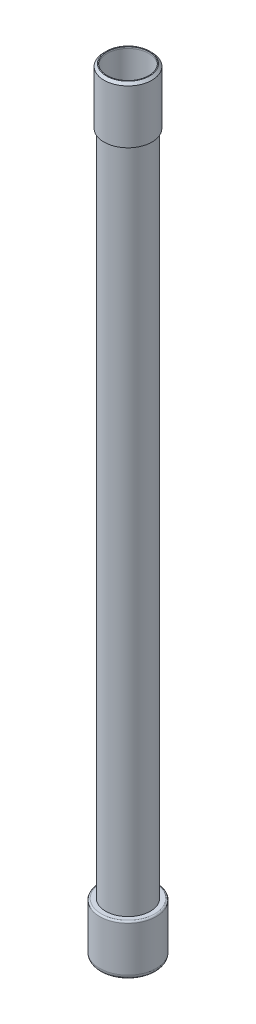
from build123d import *

# Parameters (mm, degrees)
SKETCH1_R      = 14
SKETCH1_R_2    = 13
EXTRUDE1_DEPTH = 240
FILLET1_R      = 3
FILLET2_R      = 1
CHAMFER1_SIZE  = 1.5


with BuildPart() as part:
    # Sketch1 → Extrude1 (new body, symmetric)
    with BuildSketch(Plane(origin=(0, 0, 0), x_dir=(1, 0, 0), z_dir=(0, 1, 0))):
        Circle(SKETCH1_R)
        Circle(SKETCH1_R_2, mode=Mode.SUBTRACT)
    extrude(amount=EXTRUDE1_DEPTH, both=True)


with BuildPart() as body_2:
    # Sketch2 → Revolve1 (revolve)
    with BuildSketch(Plane.XY):
        with BuildLine():
            Line((13, -211), (17.75, -211))
            Line((17.75, -211), (17.75, -242))
            ThreePointArc((17.75, -242), (9.097561486, -244.987616596), (0, -246))
            Line((0, -246), (0, -240))
            Line((0, -240), (13, -240))
            Line((13, -240), (13, -211))
        make_face()
    revolve(axis=Axis((0, -191.854456481, 0), (0, -1, 0)))

    # Fillet1
    fillet1_edges = [body_2.edges().sort_by_distance(p)[0] for p in [
        (-17.75, -242, 0),
    ]]
    fillet(fillet1_edges, radius=FILLET1_R)

    # Fillet2
    fillet2_edges = [body_2.edges().sort_by_distance(p)[0] for p in [
        (-17.75, -211, 0),
    ]]
    fillet(fillet2_edges, radius=FILLET2_R)


with BuildPart() as body_3:
    # Sketch3 → Revolve2 (revolve)
    with BuildSketch(Plane.XY):
        Polygon((15, 241), (15, 206), (14, 206), (14, 240), (13, 240), (13, 241), align=None)
    revolve(axis=Axis((0, 250.648791431, 0), (0, -1, 0)))

    # Chamfer1
    chamfer1_edges = [body_3.edges().sort_by_distance(p)[0] for p in [
        (-15, 241, 0),
    ]]
    chamfer(chamfer1_edges, length=CHAMFER1_SIZE)


solid = Compound([part.part, body_2.part, body_3.part])
